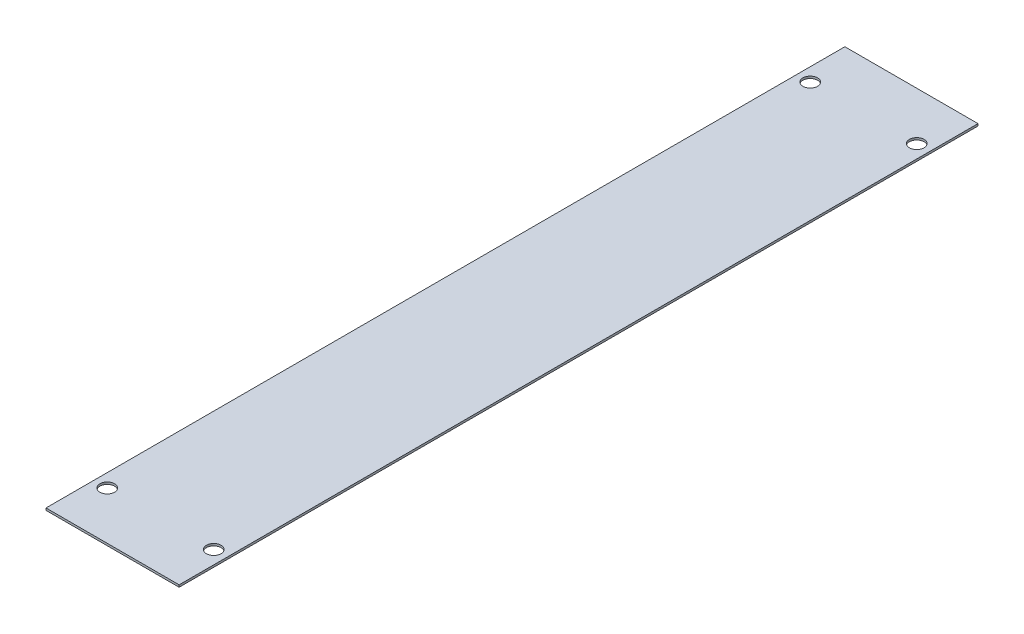
from build123d import *

# Parameters (mm, degrees)
SKETCH1_W               = 25
SKETCH1_H               = 150
BOSS_EXTRUDE1_DEPTH     = 0.4
SKETCH2_R               = 1.38
CUT_EXTRUDE1_DEPTH      = 0.4
MIRROR2_COPY_1_SKETCH_R = 1.38
MIRROR2_COPY_1_DEPTH    = 0.4


with BuildPart() as part:
    # Sketch1 → Boss-Extrude1 (new body)
    with BuildSketch(Plane(origin=(0, 0, 0), x_dir=(1, 0, 0), z_dir=(0, 1, 0))):
        Rectangle(SKETCH1_W, SKETCH1_H)
    extrude(amount=BOSS_EXTRUDE1_DEPTH)

    # Sketch2 → Cut-Extrude1 (cut)
    with BuildSketch(Plane(origin=(0, 0.4, 0), x_dir=(1, 0, 0), z_dir=(0, 1, 0))):
        with Locations((-10, 66)):
            Circle(SKETCH2_R)
    cut_extrude1 = extrude(amount=-CUT_EXTRUDE1_DEPTH, mode=Mode.SUBTRACT)

    # Mirror1: Cut-Extrude1 across plane
    add(cut_extrude1.mirror(Plane(origin=(0, 0, 0), x_dir=(0, 0, 1), z_dir=(1, 0, 0))), mode=Mode.SUBTRACT)

    # Mirror2: Cut-Extrude1 across plane
    add(cut_extrude1.mirror(Plane.XY), mode=Mode.SUBTRACT)

    # Mirror2 copy 1 sketch → Mirror2 copy 1 (cut)
    with BuildSketch(Plane(origin=(0, 0.4, 0), x_dir=(-1, 0, 0), z_dir=(0, 1, 0))):
        with Locations((-10, 66)):
            Circle(MIRROR2_COPY_1_SKETCH_R)
    extrude(amount=-MIRROR2_COPY_1_DEPTH, mode=Mode.SUBTRACT)


solid = part.part
